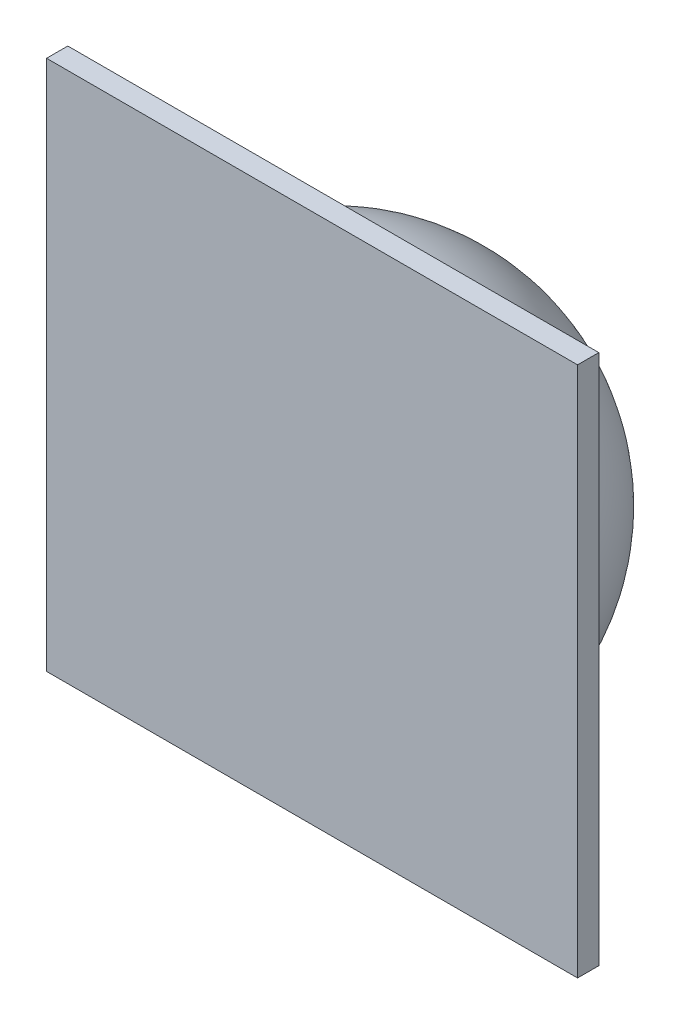
from build123d import *

# Parameters (mm, degrees)
SKETCH1_W           = 50
SKETCH1_H           = 50
BOSS_EXTRUDE1_DEPTH = 2
SCALE1_SCALE        = 0.5
SCALE2_SCALE        = 0.6
SKETCH3_W           = 2
SKETCH3_H           = 2
BOSS_EXTRUDE2_DEPTH = 2


with BuildPart() as part:
    # Sketch1 → Boss-Extrude1 (new body)
    with BuildSketch(Plane.XY):
        Rectangle(SKETCH1_W, SKETCH1_H)
    extrude(amount=BOSS_EXTRUDE1_DEPTH)

    # Sketch2 → Revolve2 (revolve)
    with BuildSketch(Plane(origin=(0, 0, 0), x_dir=(0, 0, -1), z_dir=(1, 0, 0))):
        with BuildLine():
            Line((0, -20), (0, -18))
            ThreePointArc((0, -18), (12.727922061, -12.727922061), (18, 0))
            Line((18, 0), (20, 0))
            ThreePointArc((20, 0), (14.142135624, -14.142135624), (0, -20))
        make_face()
    revolve(axis=Axis((0, 0, -18), (0, 0, -1)))


with BuildPart() as part_1:
    # Scale1: scaled about (0, 0, -4.005571342)
    add(part.part.scale(SCALE1_SCALE).moved(Location((0, 0, -2.002785671))))


with BuildPart() as part_2:
    # Scale2: scaled about (0, 0, -4.005571342)
    add(part_1.part.scale(SCALE2_SCALE).moved(Location((0, 0, -1.602228537))))

    # Sketch3 → Boss-Extrude2 (add)
    with BuildSketch(Plane(origin=(0, 0, -2.803899939), x_dir=(-1, 0, 0), z_dir=(0, 0, -1))):
        Rectangle(SKETCH3_W, SKETCH3_H)
    extrude(amount=BOSS_EXTRUDE2_DEPTH)


solid = part_2.part
